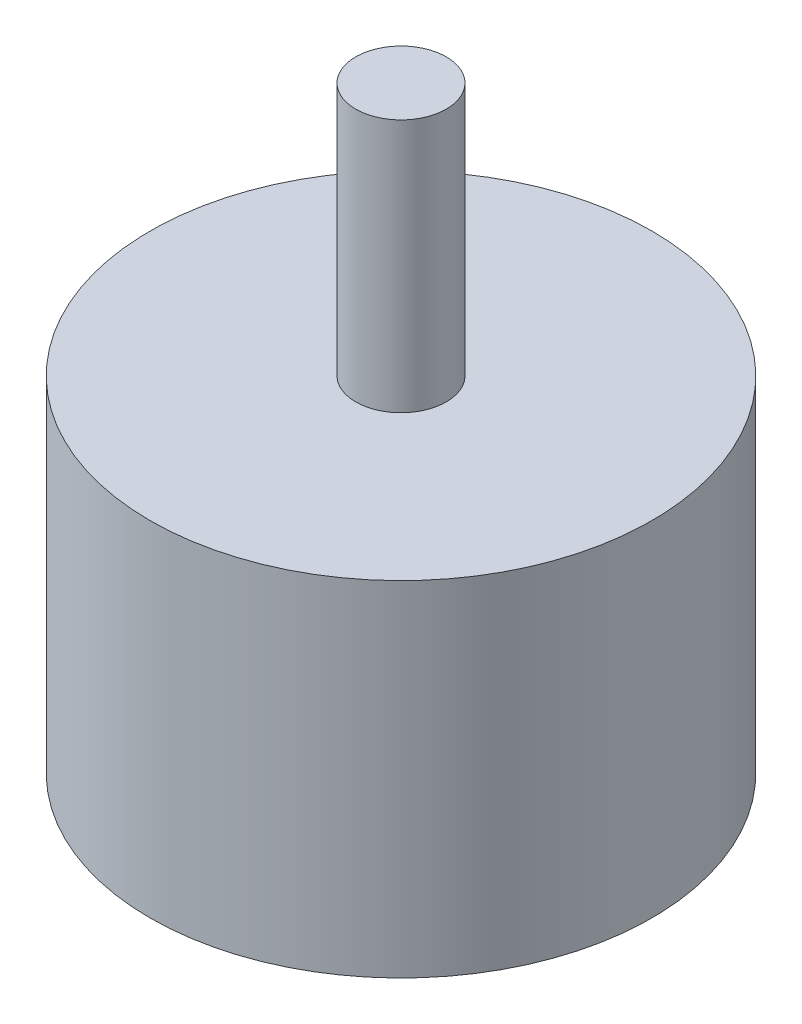
from build123d import *

# Parameters (mm, degrees)
SKETCH1_R                 = 13.85
BOSS_EXTRUDE1_DEPTH       = 19
SKETCH2_R                 = 2.5
BOSS_EXTRUDE2_DEPTH       = 14
M3X0_5_TAPPED_HOLE1_D     = 2.5
M3X0_5_TAPPED_HOLE1_DEPTH = 7.5
M3X0_5_TAPPED_HOLE1_TIP   = 0.751075774


with BuildPart() as part:
    # Sketch1 → Boss-Extrude1 (new body)
    with BuildSketch(Plane(origin=(0, 0, 0), x_dir=(1, 0, 0), z_dir=(0, 1, 0))):
        Circle(SKETCH1_R)
    extrude(amount=BOSS_EXTRUDE1_DEPTH)

    # Sketch2 → Boss-Extrude2 (add)
    with BuildSketch(Plane(origin=(0, 19, 0), x_dir=(1, 0, 0), z_dir=(0, 1, 0))):
        Circle(SKETCH2_R)
    extrude(amount=BOSS_EXTRUDE2_DEPTH)

    # M3x0.5 Tapped Hole1
    with Locations(Plane(origin=(0, 0, 0), x_dir=(-1, 0, 0), z_dir=(0, -1, 0))):
        with Locations((0, -8), (9.5, 0), (0, 8), (-9.5, 0)):
            Hole(M3X0_5_TAPPED_HOLE1_D / 2, depth=M3X0_5_TAPPED_HOLE1_DEPTH)
            with Locations((0, 0, -(M3X0_5_TAPPED_HOLE1_DEPTH + M3X0_5_TAPPED_HOLE1_TIP / 2))):  # 118° drill point
                Cone(0, M3X0_5_TAPPED_HOLE1_D / 2, M3X0_5_TAPPED_HOLE1_TIP, mode=Mode.SUBTRACT)


solid = part.part
